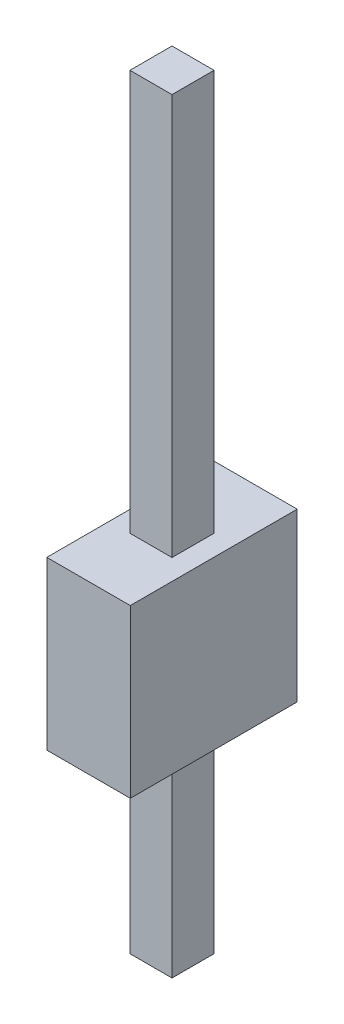
from build123d import *

# Parameters (mm, degrees)
SKETCH1_W                = 1.27
SKETCH1_H                = 2.54
BOSS_EXTRUDE1_DEPTH      = 2.54
SKETCH2_W                = 0.64
SKETCH2_H                = 0.64
BOSS_EXTRUDE2_DEPTH      = 6.1
BOSS_EXTRUDE2_DEPTH_BACK = 5.54


with BuildPart() as part:
    # Sketch1 → Boss-Extrude1 (new body)
    with BuildSketch(Plane(origin=(0, 0, 0), x_dir=(1, 0, 0), z_dir=(0, 1, 0))):
        with Locations((0.635, 1.27)):
            Rectangle(SKETCH1_W, SKETCH1_H)
    extrude(amount=BOSS_EXTRUDE1_DEPTH)

    # Sketch2 → Boss-Extrude2 (add, two sides)
    with BuildSketch(Plane(origin=(0, 2.54, 0), x_dir=(1, 0, 0), z_dir=(0, 1, 0))) as boss_extrude2_sk:
        with Locations((0.635, 1.27)):
            Rectangle(SKETCH2_W, SKETCH2_H)
    extrude(amount=BOSS_EXTRUDE2_DEPTH)
    extrude(boss_extrude2_sk.sketch, amount=-BOSS_EXTRUDE2_DEPTH_BACK)


solid = part.part
